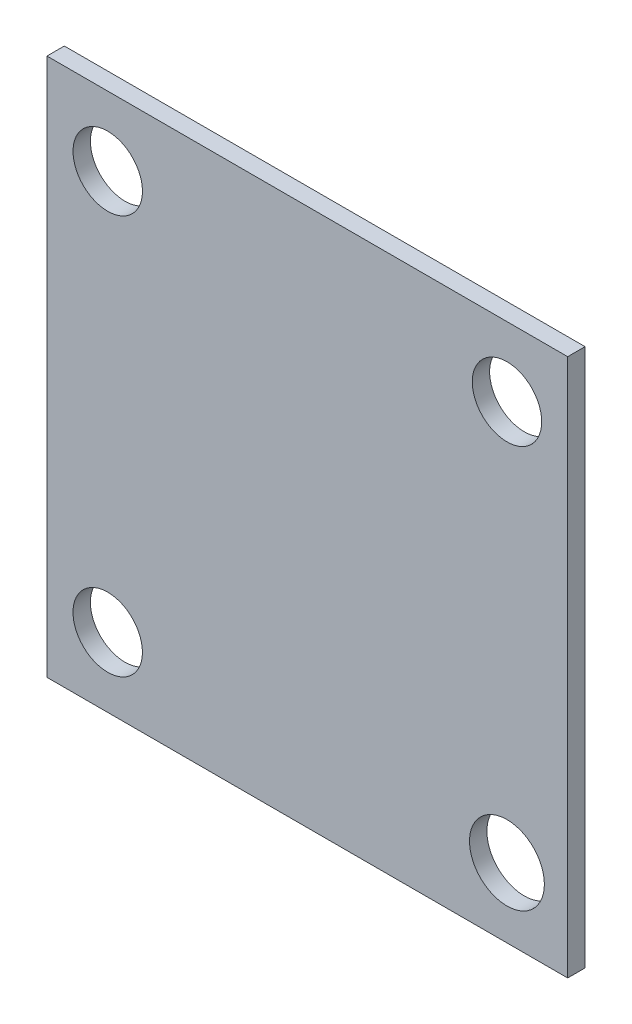
from build123d import *

# Parameters (mm, degrees)
SKETCH2_W           = 30.002183488
SKETCH2_H           = 31.002183488
SKETCH2_R           = 2
SKETCH2_R_2         = 2.156266898
BOSS_EXTRUDE1_DEPTH = 1


with BuildPart() as part:
    # Sketch2 → Boss-Extrude1 (new body)
    with BuildSketch(Plane.XY):
        Rectangle(SKETCH2_W, SKETCH2_H)
        with Locations((-11.498908256, 11.503275233)):
            Circle(SKETCH2_R, mode=Mode.SUBTRACT)
        with Locations((11.503275233, 11.501091744)):
            Circle(SKETCH2_R, mode=Mode.SUBTRACT)
        with Locations((-11.501091744, -11.498908256)):
            Circle(SKETCH2_R, mode=Mode.SUBTRACT)
        with Locations((11.501091744, -11.501091744)):
            Circle(SKETCH2_R_2, mode=Mode.SUBTRACT)
    extrude(amount=BOSS_EXTRUDE1_DEPTH)


solid = part.part
